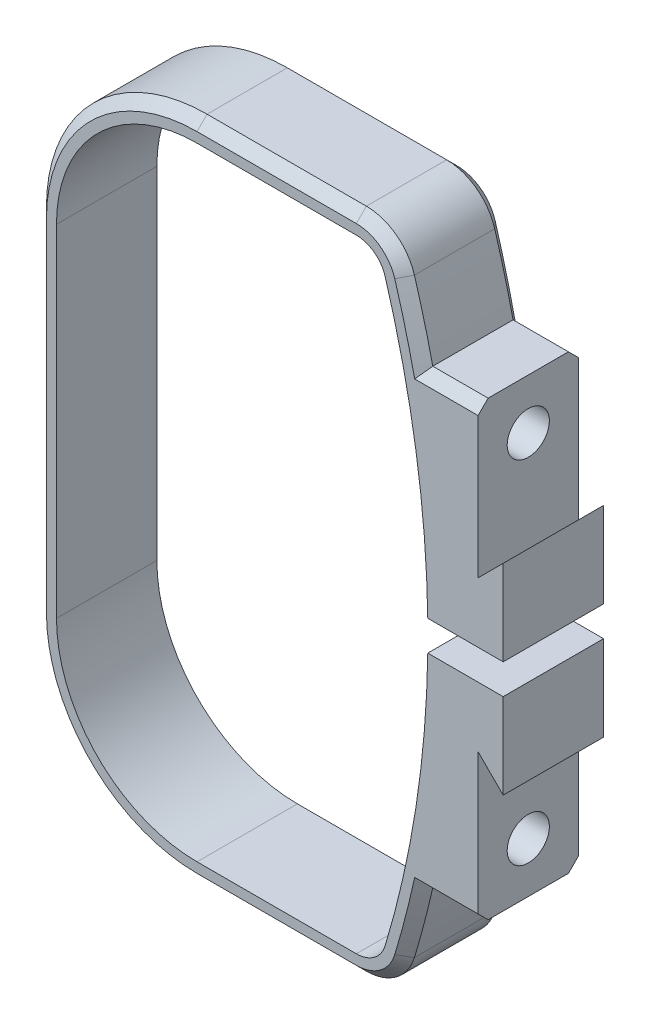
from build123d import *

# Parameters (mm, degrees)
SALIENTE_EXTRUIR1_DEPTH = 5
SALIENTE_EXTRUIR2_DEPTH = 10
CORTAR_EXTRUIR1_DEPTH   = 11
CROQUIS4_W              = 15
CROQUIS4_H              = 3
CORTAR_EXTRUIR2_DEPTH   = 11
CORTAR_EXTRUIR3_REACH   = 46
CROQUIS6_R              = 2.1
CORTAR_EXTRUIR4_REACH   = 49
CORTAR_EXTRUIR4_START   = -3
CROQUIS7_W              = 6.9
CROQUIS7_H              = 6.9
CHAFL_N1_SIZE           = 1


with BuildPart() as part:
    # Croquis1 → Saliente-Extruir1 (new body, symmetric)
    with BuildSketch(Plane.XY):
        with BuildLine():
            Line((-20.5, -17), (-20.5, 17))
            ThreePointArc((-20.5, 17), (-15.813708499, 28.313708499), (-4.5, 33))
            Line((-4.5, 33), (11.370878105, 33))
            ThreePointArc((11.370878105, 33), (14.352782292, 32.013508119), (16.15803677, 29.443298969))
            ThreePointArc((16.15803677, 29.443298969), (20.5, 0), (16.15803677, -29.443298969))
            ThreePointArc((16.15803677, -29.443298969), (14.352782292, -32.013508119), (11.370878105, -33))
            Line((11.370878105, -33), (-4.5, -33))
            ThreePointArc((-4.5, -33), (-15.813708499, -28.313708499), (-20.5, -17))
        make_face()
        with BuildLine():
            Line((-4.5, 31), (11.370878105, 31))
            ThreePointArc((11.370878105, 31), (13.160020617, 30.408104872), (14.243173304, 28.865979381))
            ThreePointArc((14.243173304, 28.865979381), (18.5, 0), (14.243173304, -28.865979381))
            ThreePointArc((14.243173304, -28.865979381), (13.160020617, -30.408104872), (11.370878105, -31))
            Line((11.370878105, -31), (-4.5, -31))
            ThreePointArc((-4.5, -31), (-14.399494937, -26.899494937), (-18.5, -17))
            Line((-18.5, -17), (-18.5, 17))
            ThreePointArc((-18.5, 17), (-14.399494937, 26.899494937), (-4.5, 31))
        make_face(mode=Mode.SUBTRACT)
    extrude(amount=SALIENTE_EXTRUIR1_DEPTH, both=True)

    # Croquis2 → Saliente-Extruir2 (add, through all)
    with BuildSketch(Plane.XY.offset(5)):
        Polygon((18.5, 22.5), (17.987436393, 22.5), (20.5, 0), (17.987436393, -22.5), (18.5, -22.5), (28.5, -22.5), (28.5, 22.5), align=None)
    extrude(amount=-SALIENTE_EXTRUIR2_DEPTH)

    # Croquis3 → Cortar-Extruir1 (cut, through all)
    with BuildSketch(Plane.XY.offset(5)):
        Polygon((23.5, 22.5), (23.5, 7.5), (26, 10), (26, -10), (23.5, -7.5), (23.5, -22.5), (28.5, -22.5), (28.5, 22.5), align=None)
    extrude(amount=-CORTAR_EXTRUIR1_DEPTH, mode=Mode.SUBTRACT)

    # Croquis4 → Cortar-Extruir2 (cut, through all)
    with BuildSketch(Plane.XY.offset(5)):
        with Locations((18.5, 0)):
            Rectangle(CROQUIS4_W, CROQUIS4_H)
    extrude(amount=-CORTAR_EXTRUIR2_DEPTH, mode=Mode.SUBTRACT)

    # Croquis6 → Cortar-Extruir3 (cut, up to next)
    with BuildSketch(Plane(origin=(23.5, 0, 0), x_dir=(0, 0, -1), z_dir=(1, 0, 0)), mode=Mode.PRIVATE) as cortar_extruir3_sk1:
        with Locations((0, 17.5)):
            Circle(CROQUIS6_R)
    cortar_extruir3_tool1 = extrude(cortar_extruir3_sk1.sketch, amount=-CORTAR_EXTRUIR3_REACH, mode=Mode.PRIVATE) & part.part
    add(cortar_extruir3_tool1.solids().sort_by_distance((23.5, 17.5, 0))[0], mode=Mode.SUBTRACT)
    # Croquis6 → Cortar-Extruir3 (cut, up to next)
    with BuildSketch(Plane(origin=(23.5, 0, 0), x_dir=(0, 0, -1), z_dir=(1, 0, 0)), mode=Mode.PRIVATE) as cortar_extruir3_sk2:
        with Locations((0, -17.5)):
            Circle(CROQUIS6_R)
    cortar_extruir3_tool2 = extrude(cortar_extruir3_sk2.sketch, amount=-CORTAR_EXTRUIR3_REACH, mode=Mode.PRIVATE) & part.part
    add(cortar_extruir3_tool2.solids().sort_by_distance((23.5, -17.5, 0))[0], mode=Mode.SUBTRACT)

    # Croquis7 → Cortar-Extruir4 (cut, up to next)
    with BuildSketch(Plane(origin=(23.5, 0, 0), x_dir=(0, 0, -1), z_dir=(1, 0, 0)).offset(CORTAR_EXTRUIR4_START), mode=Mode.PRIVATE) as cortar_extruir4_sk1:
        with Locations((0, 17.5)):
            Rectangle(CROQUIS7_W, CROQUIS7_H)
    cortar_extruir4_tool1 = extrude(cortar_extruir4_sk1.sketch, amount=-CORTAR_EXTRUIR4_REACH, mode=Mode.PRIVATE) & part.part
    add(cortar_extruir4_tool1.solids().sort_by_distance((20.5, 17.5, 0))[0], mode=Mode.SUBTRACT)
    # Croquis7 → Cortar-Extruir4 (cut, up to next)
    with BuildSketch(Plane(origin=(23.5, 0, 0), x_dir=(0, 0, -1), z_dir=(1, 0, 0)).offset(CORTAR_EXTRUIR4_START), mode=Mode.PRIVATE) as cortar_extruir4_sk2:
        with Locations((0, -17.5)):
            Rectangle(CROQUIS7_W, CROQUIS7_H)
    cortar_extruir4_tool2 = extrude(cortar_extruir4_sk2.sketch, amount=-CORTAR_EXTRUIR4_REACH, mode=Mode.PRIVATE) & part.part
    add(cortar_extruir4_tool2.solids().sort_by_distance((20.5, -17.5, 0))[0], mode=Mode.SUBTRACT)

    # Chaflán1
    chafl_n1_edges = [part.edges().sort_by_distance(p)[0] for p in [
        (3.435439053, -33, -5),
        (-15.813708499, -28.313708499, -5),
        (-20.5, 0, -5),
        (-15.813708499, 28.313708499, -5),
        (-15.813708499, -28.313708499, 5),
        (3.435439053, -33, 5),
        (14.352782292, -32.013508119, 5),
        (17.133851934, -25.987751975, 5),
        (14.352782292, 32.013508119, 5),
        (3.435439053, 33, 5),
        (-15.813708499, 28.313708499, 5),
        (17.133851934, 25.987751975, -5),
        (17.133851934, 25.987751975, 5),
        (20.743718196, -22.5, -5),
        (20.743718196, -22.5, 5),
        (20.743718196, 22.5, 5),
        (20.743718196, 22.5, -5),
        (3.435439053, 33, -5),
        (-20.5, 0, 5),
        (14.352782292, 32.013508119, -5),
        (17.133851934, -25.987751975, -5),
        (14.352782292, -32.013508119, -5),
    ]]
    chamfer(chafl_n1_edges, length=CHAFL_N1_SIZE)


solid = part.part
